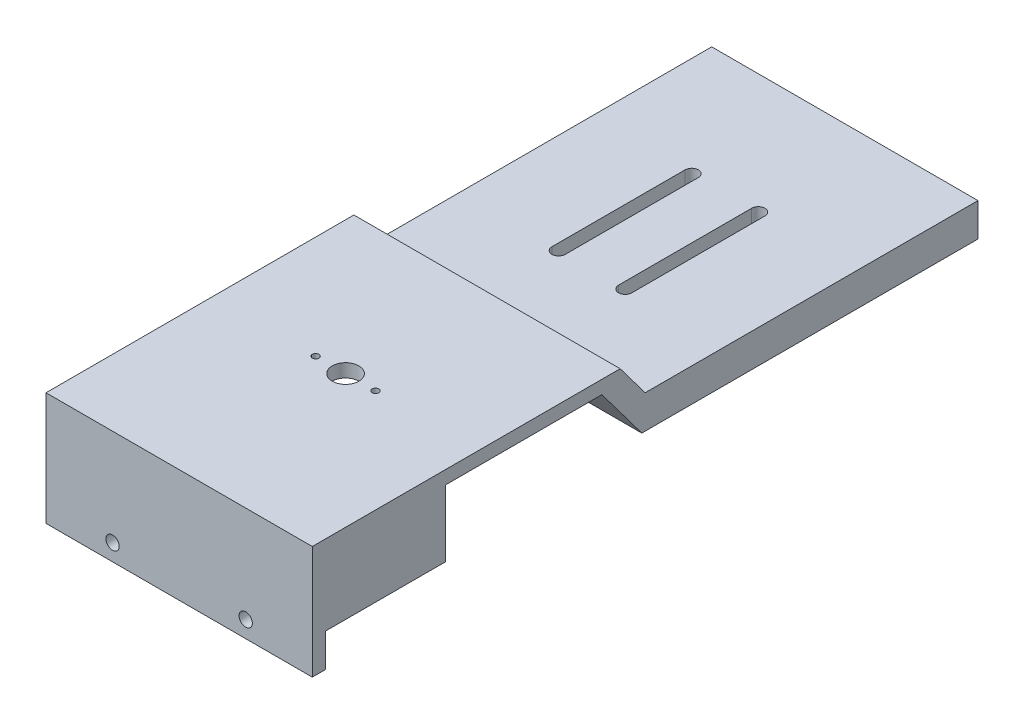
from build123d import *

# Parameters (mm, degrees)
SKETCH_1_W          = 40
SKETCH_1_H          = 12
EXTRUDE_1_DEPTH     = 20
SKETCH_2_W          = 40
SKETCH_2_H          = 2
EXTRUDE_2_DEPTH     = 23.5
SKETCH_3_W          = 40
SKETCH_3_H          = 2
EXTRUDE_3_DEPTH     = 5
CUT_EXTRUDE_1_REACH = 19
SKETCH_4_R          = 0.5
SKETCH_4_R_2        = 2
CUT_EXTRUDE_2_REACH = 4
SKETCH_5_R          = 1
EXTRUDE_4_DEPTH     = 40
CUT_EXTRUDE_3_DEPTH = 40
CUT_EXTRUDE_5_REACH = 14


with BuildPart() as part:
    # 草图1 → 凸台-拉伸1 (new body)
    with BuildSketch(Plane.XY):
        Rectangle(SKETCH_1_W, SKETCH_1_H)
    extrude(amount=EXTRUDE_1_DEPTH)

    # 草图2 → 凸台-拉伸2 (add)
    with BuildSketch(Plane(origin=(0, 0, 0), x_dir=(-1, 0, 0), z_dir=(0, 0, -1))):
        with Locations((0, 5)):
            Rectangle(SKETCH_2_W, SKETCH_2_H)
    extrude(amount=EXTRUDE_2_DEPTH)

    # 草图3 → 凸台-拉伸3 (add)
    with BuildSketch(Plane.XZ.offset(6)):
        with Locations((0, 19)):
            Rectangle(SKETCH_3_W, SKETCH_3_H)
    extrude(amount=EXTRUDE_3_DEPTH)

    # 草图4 → 切除-拉伸1 (cut, up to next)
    with BuildSketch(Plane(origin=(0, 6, 0), x_dir=(1, 0, 0), z_dir=(0, 1, 0)), mode=Mode.PRIVATE) as cut_extrude_1_sk1:
        with Locations((-4.5, 5)):
            Circle(SKETCH_4_R)
    cut_extrude_1_tool1 = extrude(cut_extrude_1_sk1.sketch, amount=-CUT_EXTRUDE_1_REACH, mode=Mode.PRIVATE) & part.part
    add(cut_extrude_1_tool1.solids().sort_by_distance((-4.5, 6, -5))[0], mode=Mode.SUBTRACT)
    # 草图4 → 切除-拉伸1 (cut, up to next)
    with BuildSketch(Plane(origin=(0, 6, 0), x_dir=(1, 0, 0), z_dir=(0, 1, 0)), mode=Mode.PRIVATE) as cut_extrude_1_sk2:
        with Locations((4.5, 5)):
            Circle(SKETCH_4_R)
    cut_extrude_1_tool2 = extrude(cut_extrude_1_sk2.sketch, amount=-CUT_EXTRUDE_1_REACH, mode=Mode.PRIVATE) & part.part
    add(cut_extrude_1_tool2.solids().sort_by_distance((4.5, 6, -5))[0], mode=Mode.SUBTRACT)
    # 草图4 → 切除-拉伸1 (cut, up to next)
    with BuildSketch(Plane(origin=(0, 6, 0), x_dir=(1, 0, 0), z_dir=(0, 1, 0)), mode=Mode.PRIVATE) as cut_extrude_1_sk3:
        with Locations((0, 5)):
            Circle(SKETCH_4_R_2)
    cut_extrude_1_tool3 = extrude(cut_extrude_1_sk3.sketch, amount=-CUT_EXTRUDE_1_REACH, mode=Mode.PRIVATE) & part.part
    add(cut_extrude_1_tool3.solids().sort_by_distance((0, 6, -5))[0], mode=Mode.SUBTRACT)

    # 草图5 → 切除-拉伸2 (cut, up to next)
    with BuildSketch(Plane(origin=(0, 0, 18), x_dir=(-1, 0, 0), z_dir=(0, 0, -1)), mode=Mode.PRIVATE) as cut_extrude_2_sk1:
        with Locations((-10, -8.5)):
            Circle(SKETCH_5_R)
    cut_extrude_2_tool1 = extrude(cut_extrude_2_sk1.sketch, amount=-CUT_EXTRUDE_2_REACH, mode=Mode.PRIVATE) & part.part
    add(cut_extrude_2_tool1.solids().sort_by_distance((10, -8.5, 18))[0], mode=Mode.SUBTRACT)
    # 草图5 → 切除-拉伸2 (cut, up to next)
    with BuildSketch(Plane(origin=(0, 0, 18), x_dir=(-1, 0, 0), z_dir=(0, 0, -1)), mode=Mode.PRIVATE) as cut_extrude_2_sk2:
        with Locations((10, -8.5)):
            Circle(SKETCH_5_R)
    cut_extrude_2_tool2 = extrude(cut_extrude_2_sk2.sketch, amount=-CUT_EXTRUDE_2_REACH, mode=Mode.PRIVATE) & part.part
    add(cut_extrude_2_tool2.solids().sort_by_distance((-10, -8.5, 18))[0], mode=Mode.SUBTRACT)

    # 草图6 → 凸台-拉伸4 (add)
    with BuildSketch(Plane(origin=(20, 0, 0), x_dir=(0, 0, -1), z_dir=(1, 0, 0))):
        Polygon((23.5, 4), (29.5, -4), (80, -4), (80, 6), (23.5, 6), align=None)
    extrude(amount=-EXTRUDE_4_DEPTH)

    # 草图7 → 切除-拉伸3 (cut)
    with BuildSketch(Plane.ZY.offset(20)):
        Polygon((-30, 1), (-26.25, 6), (-80, 6), (-80, 1), align=None)
    extrude(amount=-CUT_EXTRUDE_3_DEPTH, mode=Mode.SUBTRACT)

    # 草图9 → 切除-拉伸5 (cut, up to next)
    with BuildSketch(Plane(origin=(0, 1, 0), x_dir=(1, 0, 0), z_dir=(0, 1, 0)), mode=Mode.PRIVATE) as cut_extrude_5_sk1:
        with BuildLine():
            Line((-4, 62), (-4, 42))
            ThreePointArc((-4, 42), (-5, 41), (-6, 42))
            Line((-6, 42), (-6, 62))
            ThreePointArc((-6, 62), (-5, 63), (-4, 62))
        make_face()
    cut_extrude_5_tool1 = extrude(cut_extrude_5_sk1.sketch, amount=-CUT_EXTRUDE_5_REACH, mode=Mode.PRIVATE) & part.part
    add(cut_extrude_5_tool1.solids().sort_by_distance((-5, 1, -52))[0], mode=Mode.SUBTRACT)
    # 草图9 → 切除-拉伸5 (cut, up to next)
    with BuildSketch(Plane(origin=(0, 1, 0), x_dir=(1, 0, 0), z_dir=(0, 1, 0)), mode=Mode.PRIVATE) as cut_extrude_5_sk2:
        with BuildLine():
            Line((4, 62), (4, 42))
            ThreePointArc((4, 42), (5, 41), (6, 42))
            Line((6, 42), (6, 62))
            ThreePointArc((6, 62), (5, 63), (4, 62))
        make_face()
    cut_extrude_5_tool2 = extrude(cut_extrude_5_sk2.sketch, amount=-CUT_EXTRUDE_5_REACH, mode=Mode.PRIVATE) & part.part
    add(cut_extrude_5_tool2.solids().sort_by_distance((5, 1, -52))[0], mode=Mode.SUBTRACT)


solid = part.part
